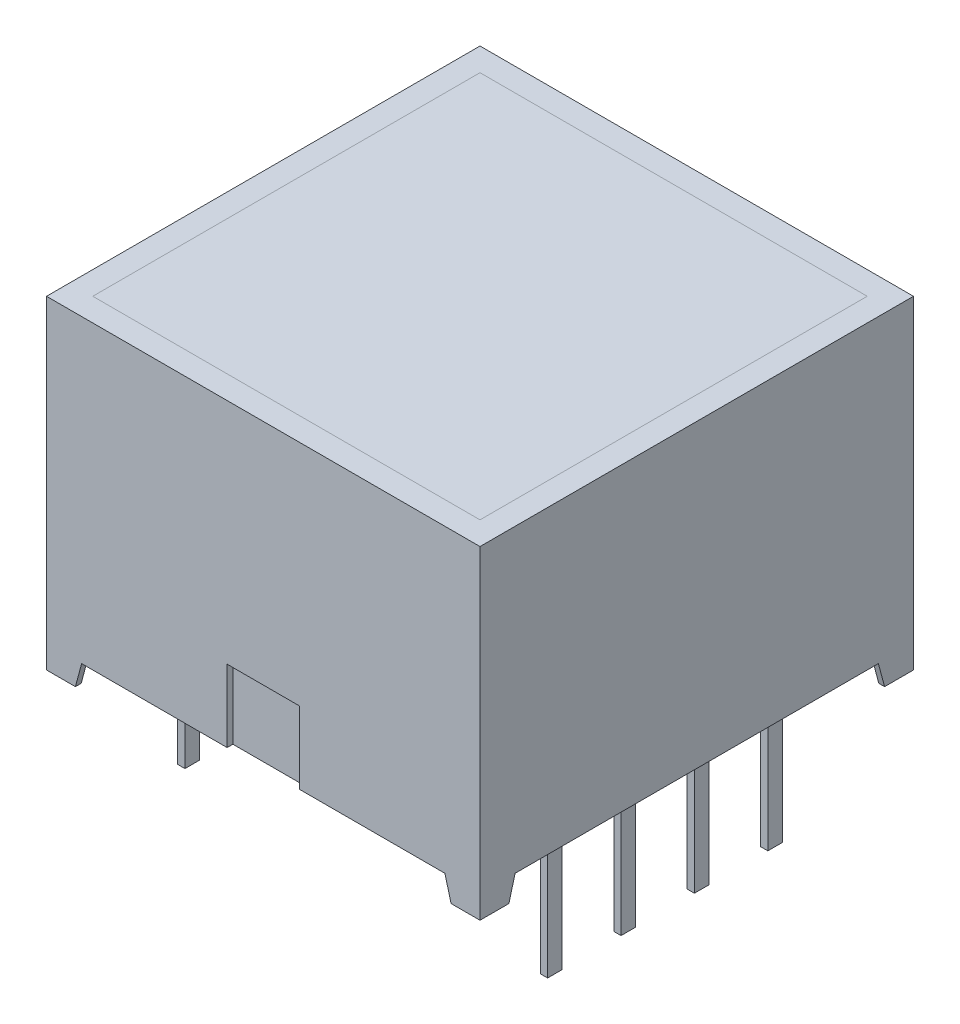
from build123d import *

# Parameters (mm, degrees)
EXTRUDE1_DEPTH     = 7.5
CUT_EXTRUDE1_DEPTH = 16
SKETCH2_W          = 13.4
SKETCH2_H          = 13.4
CUT_EXTRUDE2_DEPTH = 5.6
SKETCH4_W          = 0.25
SKETCH4_H          = 0.5
EXTRUDE2_DEPTH     = 0.8
SKETCH4_3_W        = 0.25
SKETCH4_3_H        = 0.5
EXTRUDE3_DEPTH     = 4
SKETCH4_4_W        = 1.014359354
SKETCH4_4_H        = 1.014359354
CUT_EXTRUDE3_DEPTH = 0.8
SKETCH2_3_W        = 13.4
SKETCH2_3_H        = 13.4
EXTRUDE4_DEPTH     = 5.6
SKETCH5_W          = 2.5
SKETCH5_H          = 2.5
CUT_EXTRUDE4_DEPTH = 0.2
SKETCH6_W          = 0.025316455
SKETCH6_H          = 0.026582279
CUT_EXTRUDE5_DEPTH = 0.01


with BuildPart() as part:
    # Sketch1 → Extrude1 (new body, symmetric)
    with BuildSketch(Plane(origin=(0, 0, 0), x_dir=(0, 0, -1), z_dir=(1, 0, 0))):
        Polygon((7.5, 5.6), (-7.5, 5.6), (7.5, -5.6), align=None)
        Polygon((7.5, -5.6), (-7.5, 5.6), (-7.5, -5.6), (-6.5, -5.6), (-6.285640646, -4.8), (6.285640646, -4.8), (6.5, -5.6), align=None)
    extrude(amount=EXTRUDE1_DEPTH, both=True)

    # Sketch3 → Cut-Extrude1 (cut, through all)
    with BuildSketch(Plane.XY.offset(7.5)):
        Polygon((-6.285640646, -4.8), (-6.5, -5.6), (6.5, -5.6), (6.285640646, -4.8), align=None)
    extrude(amount=-CUT_EXTRUDE1_DEPTH, mode=Mode.SUBTRACT)

    # Sketch2 → Cut-Extrude2 (cut)
    with BuildSketch(Plane(origin=(0, 5.6, 0), x_dir=(-1, 0, 0), z_dir=(0, 1, 0))):
        Rectangle(SKETCH2_W, SKETCH2_H)
    extrude(amount=-CUT_EXTRUDE2_DEPTH, mode=Mode.SUBTRACT)

    # Sketch4 → Extrude2 (add)
    with BuildSketch(Plane.XZ.offset(5.6)):
        with Locations((-6.275, 3.81)):
            Rectangle(SKETCH4_W, SKETCH4_H)
        with Locations((-6.275, 1.27)):
            Rectangle(SKETCH4_W, SKETCH4_H)
        with Locations((-6.275, -3.81)):
            Rectangle(SKETCH4_W, SKETCH4_H)
        with Locations((-6.275, -1.27)):
            Rectangle(SKETCH4_W, SKETCH4_H)
        with Locations((6.275, -3.81)):
            Rectangle(SKETCH4_W, SKETCH4_H)
        with Locations((6.275, -1.27)):
            Rectangle(SKETCH4_W, SKETCH4_H)
        with Locations((6.275, 1.27)):
            Rectangle(SKETCH4_W, SKETCH4_H)
        with Locations((6.275, 3.81)):
            Rectangle(SKETCH4_W, SKETCH4_H)
    extrude(amount=-EXTRUDE2_DEPTH)

    # Sketch4_3 → Extrude3 (add)
    with BuildSketch(Plane.XZ.offset(5.6)):
        with Locations((-6.275, 3.81)):
            Rectangle(SKETCH4_3_W, SKETCH4_3_H)
        with Locations((-6.275, 1.27)):
            Rectangle(SKETCH4_3_W, SKETCH4_3_H)
        with Locations((-6.275, -3.81)):
            Rectangle(SKETCH4_3_W, SKETCH4_3_H)
        with Locations((-6.275, -1.27)):
            Rectangle(SKETCH4_3_W, SKETCH4_3_H)
        with Locations((6.275, -3.81)):
            Rectangle(SKETCH4_3_W, SKETCH4_3_H)
        with Locations((6.275, -1.27)):
            Rectangle(SKETCH4_3_W, SKETCH4_3_H)
        with Locations((6.275, 1.27)):
            Rectangle(SKETCH4_3_W, SKETCH4_3_H)
        with Locations((6.275, 3.81)):
            Rectangle(SKETCH4_3_W, SKETCH4_3_H)
    extrude(amount=EXTRUDE3_DEPTH)

    # Sketch4_4 → Cut-Extrude3 (cut)
    with BuildSketch(Plane.XZ.offset(5.6)):
        with Locations((6.792820323, -6.792820323)):
            Rectangle(SKETCH4_4_W, SKETCH4_4_H)
        with Locations((-6.792820323, 6.792820323)):
            Rectangle(SKETCH4_4_W, SKETCH4_4_H)
        with Locations((6.792820323, 6.792820323)):
            Rectangle(SKETCH4_4_W, SKETCH4_4_H)
        with Locations((-6.792820323, -6.792820323)):
            Rectangle(SKETCH4_4_W, SKETCH4_4_H)
    extrude(amount=-CUT_EXTRUDE3_DEPTH, mode=Mode.SUBTRACT)

    # Sketch5 → Cut-Extrude4 (cut)
    with BuildSketch(Plane(origin=(0, 0, 7.5), x_dir=(-1, 0, 0), z_dir=(0, 0, -1))):
        with Locations((0, -3.55)):
            Rectangle(SKETCH5_W, SKETCH5_H)
    extrude(amount=CUT_EXTRUDE4_DEPTH, mode=Mode.SUBTRACT)

    # Sketch6 → Cut-Extrude5 (cut)
    with BuildSketch(Plane.XZ.offset(4.8)):
        Polygon((-0.663098825, -6.351662565), (-0.686556104, -6.426346109), (-0.711298983, -6.426346109), (-0.727715122, -6.376009875), (-0.74324123, -6.426346109), (-0.768973034, -6.426346109), (-0.792212749, -6.351662565), (-0.767034743, -6.351662565), (-0.754040281, -6.403145951), (-0.737624141, -6.351662565), (-0.716124933, -6.351662565), (-0.699807686, -6.403145951), (-0.68699123, -6.351662565), align=None)
        Polygon((-0.52892161, -6.351662565), (-0.552378888, -6.426346109), (-0.577121768, -6.426346109), (-0.593537907, -6.376009875), (-0.609064015, -6.426346109), (-0.634795819, -6.426346109), (-0.658035534, -6.351662565), (-0.632857528, -6.351662565), (-0.619863066, -6.403145951), (-0.603446926, -6.351662565), (-0.581947717, -6.351662565), (-0.565630471, -6.403145951), (-0.552814015, -6.351662565), align=None)
        Polygon((-0.394744395, -6.351662565), (-0.418201673, -6.426346109), (-0.442944553, -6.426346109), (-0.459360692, -6.376009875), (-0.4748868, -6.426346109), (-0.500618604, -6.426346109), (-0.523858319, -6.351662565), (-0.498680312, -6.351662565), (-0.48568585, -6.403145951), (-0.469269711, -6.351662565), (-0.447770502, -6.351662565), (-0.431453255, -6.403145951), (-0.4186368, -6.351662565), align=None)
        with Locations((-0.366896294, -6.41305497)):
            Rectangle(SKETCH6_W, SKETCH6_H)
        with BuildLine():
            add(Edge.make_bspline(
                [(-0.250440597, -6.395175223), (-0.250477086, -6.396397364), (-0.250548739, -6.398797242), (-0.251158456, -6.402304821), (-0.252151942, -6.405629526), (-0.25352606, -6.408792186), (-0.255314863, -6.411770805), (-0.257524453, -6.414551082), (-0.260088866, -6.417185882), (-0.263055075, -6.419592012), (-0.266335185, -6.421796389), (-0.269932761, -6.423693388), (-0.273811465, -6.425289871), (-0.277960051, -6.426628422), (-0.28240649, -6.427617003), (-0.28712402, -6.428340948), (-0.292117439, -6.428814278), (-0.295541017, -6.428856244), (-0.297295819, -6.428877755)],
                knots=[0, 0, 0, 0, 0.907352243, 1.781736951, 2.63548328, 3.47985091, 4.336556021, 5.208523475, 6.112432747, 7.062451073, 8.040435374, 9.043840564, 10.077958095, 11.152835584, 12.277940427, 13.457536469, 14.696825396, 16, 16, 16, 16], degree=3))
            add(Edge.make_bspline(
                [(-0.297295819, -6.428877755), (-0.299314074, -6.428853683), (-0.303223256, -6.428807058), (-0.308886781, -6.428378459), (-0.314154819, -6.42773232), (-0.319050533, -6.426765778), (-0.323655133, -6.425565013), (-0.3280884, -6.424273721), (-0.332369712, -6.422809306), (-0.335142802, -6.421709148), (-0.336516547, -6.421164147)],
                knots=[0, 0, 0, 0, 1.203215828, 2.33052265, 3.384689099, 4.366106119, 5.303329643, 6.221311756, 7.118865988, 8, 8, 8, 8], degree=3))
            Line((-0.336516547, -6.421164147), (-0.336516547, -6.397232185))
            Line((-0.336516547, -6.397232185), (-0.333668445, -6.397232185))
            add(Edge.make_bspline(
                [(-0.333668445, -6.397232185), (-0.332303131, -6.39831364), (-0.329580519, -6.400470201), (-0.325147286, -6.403232806), (-0.32049964, -6.405634969), (-0.315654169, -6.407608971), (-0.310757324, -6.409195295), (-0.305881947, -6.410288822), (-0.301116359, -6.411036171), (-0.29795779, -6.411116678), (-0.296405787, -6.411156236)],
                knots=[0, 0, 0, 0, 1.030622468, 2.055194264, 3.087043286, 4.125157485, 5.149848264, 6.130935704, 7.081611712, 8, 8, 8, 8], degree=3))
            add(Edge.make_bspline(
                [(-0.296405787, -6.411156236), (-0.295977011, -6.411155312), (-0.295059034, -6.411153335), (-0.293597507, -6.411025607), (-0.291945696, -6.410930031), (-0.290173188, -6.410722847), (-0.288376461, -6.410500986), (-0.28671406, -6.410126061), (-0.285204465, -6.409761194), (-0.284297944, -6.409393196), (-0.28386623, -6.409217944)],
                knots=[0, 0, 0, 0, 0.806402781, 1.726445712, 2.758724871, 3.919014682, 5.083870887, 6.16165551, 7.124521387, 8, 8, 8, 8], degree=3))
            add(Edge.make_bspline(
                [(-0.28386623, -6.409217944), (-0.283386667, -6.408989803), (-0.282444224, -6.408541455), (-0.281150624, -6.407731137), (-0.279982944, -6.406847672), (-0.278925573, -6.405882741), (-0.278051292, -6.404716991), (-0.277427425, -6.403308318), (-0.277082533, -6.4016593), (-0.277043509, -6.400484097), (-0.277022876, -6.399862723)],
                knots=[0, 0, 0, 0, 1.024747072, 2.013846092, 2.940605744, 3.850156746, 4.769278501, 5.73222711, 6.800942666, 8, 8, 8, 8], degree=3))
            add(Edge.make_bspline(
                [(-0.277022876, -6.399862723), (-0.27705472, -6.399317086), (-0.277117336, -6.398244202), (-0.277694529, -6.396709087), (-0.278603967, -6.395299919), (-0.279885558, -6.394031144), (-0.281478733, -6.392881611), (-0.283421117, -6.391899305), (-0.285671238, -6.391026118), (-0.287315309, -6.39060814), (-0.288177939, -6.39038883)],
                knots=[0, 0, 0, 0, 0.82557554, 1.623324704, 2.456147571, 3.35491006, 4.343819762, 5.427079081, 6.650009487, 8, 8, 8, 8], degree=3))
            add(Edge.make_bspline(
                [(-0.288177939, -6.39038883), (-0.290146565, -6.38994059), (-0.294185575, -6.38902094), (-0.3003354, -6.387882186), (-0.306463751, -6.386607326), (-0.310416517, -6.385400683), (-0.312347243, -6.384811299)],
                knots=[0, 0, 0, 0, 0.976100998, 2.002656142, 3.024398856, 4, 4, 4, 4], degree=3))
            add(Edge.make_bspline(
                [(-0.312347243, -6.384811299), (-0.313385761, -6.384458309), (-0.315407334, -6.383771181), (-0.318298845, -6.382609521), (-0.320960073, -6.381339691), (-0.323399786, -6.379984136), (-0.325600475, -6.378511596), (-0.327594743, -6.376970219), (-0.329357859, -6.375330179), (-0.330904664, -6.373590413), (-0.332229567, -6.37173971), (-0.333381952, -6.369794512), (-0.334364572, -6.367739093), (-0.33514261, -6.36556887), (-0.335767249, -6.363295214), (-0.336186231, -6.360917502), (-0.336485248, -6.358434373), (-0.336505972, -6.356739988), (-0.336516547, -6.355875381)],
                knots=[0, 0, 0, 0, 1.287047841, 2.5053592, 3.654260482, 4.74538952, 5.777514103, 6.75871007, 7.700244599, 8.599107454, 9.48590269, 10.366941872, 11.24940663, 12.154970331, 13.068988358, 14.012872203, 14.986013017, 16, 16, 16, 16], degree=3))
            add(Edge.make_bspline(
                [(-0.336516547, -6.355875381), (-0.336479245, -6.354719236), (-0.336405835, -6.352443964), (-0.335804406, -6.34911492), (-0.334777817, -6.345966183), (-0.333391753, -6.34296272), (-0.331563125, -6.340149634), (-0.329378331, -6.337471087), (-0.326754283, -6.334999495), (-0.323777162, -6.332699162), (-0.320489777, -6.330619763), (-0.316950794, -6.328789207), (-0.313181505, -6.327252555), (-0.309195958, -6.325978661), (-0.304977489, -6.32502399), (-0.300540256, -6.324305059), (-0.295866468, -6.323891877), (-0.292675046, -6.323840627), (-0.291045819, -6.323814463)],
                knots=[0, 0, 0, 0, 0.894990994, 1.761326291, 2.609044902, 3.454222546, 4.315366365, 5.200560057, 6.125081389, 7.100429509, 8.110379559, 9.133447974, 10.182136699, 11.259192205, 12.370181258, 13.528580438, 14.738335141, 16, 16, 16, 16], degree=3))
            add(Edge.make_bspline(
                [(-0.291045819, -6.323814463), (-0.289377125, -6.323836616), (-0.286042566, -6.323880884), (-0.281061227, -6.324259441), (-0.276106798, -6.324811753), (-0.271244374, -6.325660993), (-0.266552211, -6.326629225), (-0.262133096, -6.327728498), (-0.258053544, -6.328966005), (-0.255479891, -6.329920406), (-0.254238066, -6.330380919)],
                knots=[0, 0, 0, 0, 1.065407564, 2.129008667, 3.188544425, 4.247469455, 5.279542408, 6.247502114, 7.154394069, 8, 8, 8, 8], degree=3))
            Line((-0.254238066, -6.330380919), (-0.254238066, -6.352928387))
            Line((-0.254238066, -6.352928387), (-0.257066388, -6.352928387))
            add(Edge.make_bspline(
                [(-0.257066388, -6.352928387), (-0.258139892, -6.3521291), (-0.260330669, -6.350497934), (-0.263980273, -6.348396199), (-0.267947893, -6.346456107), (-0.27222952, -6.34476445), (-0.2766893, -6.343306443), (-0.281272059, -6.342286885), (-0.285898275, -6.341645178), (-0.288999979, -6.341572389), (-0.290551357, -6.341535982)],
                knots=[0, 0, 0, 0, 0.892265782, 1.820912499, 2.804518821, 3.836954028, 4.889985052, 5.931488012, 6.965393252, 8, 8, 8, 8], degree=3))
            add(Edge.make_bspline(
                [(-0.290551357, -6.341535982), (-0.291646962, -6.341557885), (-0.293844605, -6.341601819), (-0.297113797, -6.341986705), (-0.300354275, -6.342625557), (-0.302388957, -6.343441609), (-0.303407369, -6.343850065)],
                knots=[0, 0, 0, 0, 0.999122297, 2.004111588, 3.001004448, 4, 4, 4, 4], degree=3))
            add(Edge.make_bspline(
                [(-0.303407369, -6.343850065), (-0.303841099, -6.344051244), (-0.304708269, -6.344453467), (-0.305915811, -6.345233093), (-0.307036783, -6.346149436), (-0.308032365, -6.347202193), (-0.308876799, -6.348370547), (-0.309495826, -6.34963813), (-0.309870318, -6.351002011), (-0.309912665, -6.35193711), (-0.309934268, -6.352414147)],
                knots=[0, 0, 0, 0, 1.004925302, 2.009180302, 3.014392739, 4.04465309, 5.049195417, 6.035570224, 6.99785458, 8, 8, 8, 8], degree=3))
            add(Edge.make_bspline(
                [(-0.309934268, -6.352414147), (-0.30989983, -6.353052312), (-0.309834022, -6.354271788), (-0.309227437, -6.355987584), (-0.308242604, -6.357466018), (-0.307081999, -6.358460938), (-0.30596487, -6.359158376), (-0.30492921, -6.359668886), (-0.303719983, -6.360152245), (-0.302348735, -6.360649714), (-0.300812408, -6.361140901), (-0.299103851, -6.361616448), (-0.297221134, -6.362065744), (-0.295905259, -6.362351934), (-0.295219078, -6.362501172)],
                knots=[0, 0, 0, 0, 1.173816843, 2.243057204, 3.312297565, 4.415174738, 5.03266065, 5.73970059, 6.541434878, 7.433956553, 8.430083051, 9.515931566, 10.70464786, 12, 12, 12, 12], degree=3))
            add(Edge.make_bspline(
                [(-0.295219078, -6.362501172), (-0.293386156, -6.362876617), (-0.289791189, -6.363612988), (-0.284391965, -6.364725353), (-0.278886977, -6.365990712), (-0.275215826, -6.367142708), (-0.273304521, -6.36774247)],
                knots=[0, 0, 0, 0, 0.995749986, 1.952994291, 2.934271555, 4, 4, 4, 4], degree=3))
            add(Edge.make_bspline(
                [(-0.273304521, -6.36774247), (-0.272358033, -6.368061829), (-0.270506549, -6.368686546), (-0.267865002, -6.36977123), (-0.265415949, -6.37095332), (-0.263137678, -6.372175806), (-0.261075597, -6.373539022), (-0.259182373, -6.37495367), (-0.257499354, -6.376481778), (-0.256001405, -6.378094637), (-0.254683004, -6.379805069), (-0.25354804, -6.381643171), (-0.252584894, -6.3835977), (-0.251776763, -6.385670772), (-0.251198746, -6.38787784), (-0.250764688, -6.390204141), (-0.250473866, -6.392649456), (-0.250451811, -6.394323903), (-0.250440597, -6.395175223)],
                knots=[0, 0, 0, 0, 1.237386967, 2.420528625, 3.534815053, 4.605870898, 5.620827102, 6.594482803, 7.531295079, 8.432978826, 9.318460435, 10.202471551, 11.10474705, 12.014900263, 12.954095338, 13.926516828, 14.945802342, 16, 16, 16, 16], degree=3))
        make_face()
        with BuildLine():
            Line((-0.158035534, -6.426346109), (-0.182086167, -6.426346109))
            Line((-0.182086167, -6.426346109), (-0.182086167, -6.41851383))
            add(Edge.make_bspline(
                [(-0.182086167, -6.41851383), (-0.183179422, -6.419322498), (-0.185287202, -6.420881596), (-0.188460942, -6.422960361), (-0.191489663, -6.424743523), (-0.194411264, -6.426285675), (-0.197426619, -6.427476523), (-0.200654122, -6.428298379), (-0.204156386, -6.428799498), (-0.20658336, -6.42885109), (-0.207837749, -6.428877755)],
                knots=[0, 0, 0, 0, 1.150906677, 2.218931226, 3.20955724, 4.125565256, 5.012676028, 5.946647191, 6.938718366, 8, 8, 8, 8], degree=3))
            add(Edge.make_bspline(
                [(-0.207837749, -6.428877755), (-0.208854094, -6.428855025), (-0.210833212, -6.428810765), (-0.213710542, -6.428466028), (-0.216417853, -6.427927881), (-0.218934003, -6.427122025), (-0.221299349, -6.426147909), (-0.223450867, -6.424888821), (-0.225438556, -6.423429484), (-0.227241934, -6.421752549), (-0.228832553, -6.419831587), (-0.230219604, -6.417708836), (-0.231395416, -6.415374197), (-0.232337054, -6.412822831), (-0.233091987, -6.410064386), (-0.233615965, -6.40708518), (-0.233936544, -6.40389804), (-0.233968485, -6.401702912), (-0.233984901, -6.400574748)],
                knots=[0, 0, 0, 0, 1.108935798, 2.159418225, 3.158520219, 4.116592843, 5.038730546, 5.944611115, 6.829677354, 7.725673622, 8.624842385, 9.544872214, 10.487719724, 11.471363217, 12.50822837, 13.604887271, 14.769056852, 16, 16, 16, 16], degree=3))
            Line((-0.233984901, -6.400574748), (-0.233984901, -6.351662565))
            Line((-0.233984901, -6.351662565), (-0.209934268, -6.351662565))
            Line((-0.209934268, -6.351662565), (-0.209934268, -6.389241679))
            add(Edge.make_bspline(
                [(-0.209934268, -6.389241679), (-0.209932633, -6.39015815), (-0.209929502, -6.391912365), (-0.209847163, -6.394418172), (-0.209726262, -6.396686344), (-0.209587558, -6.398728373), (-0.209334541, -6.400575124), (-0.208956833, -6.402241285), (-0.208486007, -6.403760887), (-0.208021688, -6.404667588), (-0.207798192, -6.40510402)],
                knots=[0, 0, 0, 0, 1.361401701, 2.605856924, 3.723918663, 4.735739235, 5.645738665, 6.489217889, 7.27279937, 8, 8, 8, 8], degree=3))
            add(Edge.make_bspline(
                [(-0.207798192, -6.40510402), (-0.207568152, -6.405502668), (-0.207115914, -6.406286375), (-0.206196103, -6.407293523), (-0.20512012, -6.40813043), (-0.203850481, -6.408803074), (-0.2023574, -6.409286777), (-0.200625399, -6.409633524), (-0.198639384, -6.409847348), (-0.197230465, -6.40987551), (-0.196484901, -6.409890413)],
                knots=[0, 0, 0, 0, 0.849057291, 1.669173542, 2.503217716, 3.359509317, 4.311793648, 5.394940091, 6.621469141, 8, 8, 8, 8], degree=3))
            add(Edge.make_bspline(
                [(-0.196484901, -6.409890413), (-0.195943636, -6.409872955), (-0.194830759, -6.409837062), (-0.193125547, -6.409607133), (-0.191336518, -6.409245477), (-0.188822321, -6.408586454), (-0.185646176, -6.407407275), (-0.183282037, -6.406048474), (-0.182086167, -6.405361141)],
                knots=[0, 0, 0, 0, 0.638164724, 1.312110757, 2.025558264, 2.789159289, 4.375836335, 6, 6, 6, 6], degree=3))
            Line((-0.182086167, -6.405361141), (-0.182086167, -6.351662565))
            Line((-0.182086167, -6.351662565), (-0.158035534, -6.351662565))
            Line((-0.158035534, -6.351662565), (-0.158035534, -6.426346109))
        make_face()
        with BuildLine():
            Line((-0.060567179, -6.426346109), (-0.084617812, -6.426346109))
            Line((-0.084617812, -6.426346109), (-0.084617812, -6.388766995))
            add(Edge.make_bspline(
                [(-0.084617812, -6.388766995), (-0.084638137, -6.387236522), (-0.084678672, -6.384184109), (-0.085012251, -6.380427334), (-0.085345961, -6.377579543), (-0.085722784, -6.375743476), (-0.08615297, -6.37419514), (-0.086565416, -6.373309403), (-0.086753888, -6.372904653)],
                knots=[0, 0, 0, 0, 1.709235885, 3.408940626, 4.211008593, 4.910095588, 5.501954032, 6, 6, 6, 6], degree=3))
            add(Edge.make_bspline(
                [(-0.086753888, -6.372904653), (-0.086998317, -6.372506531), (-0.087477553, -6.371725956), (-0.088415369, -6.370713934), (-0.089512018, -6.36987772), (-0.090790741, -6.36921277), (-0.092275395, -6.368726872), (-0.093988069, -6.368340213), (-0.095974039, -6.368171653), (-0.097381408, -6.368136743), (-0.098126515, -6.368118261)],
                knots=[0, 0, 0, 0, 0.860145871, 1.686437142, 2.528070002, 3.393017362, 4.331453407, 5.402595683, 6.624848233, 8, 8, 8, 8], degree=3))
            add(Edge.make_bspline(
                [(-0.098126515, -6.368118261), (-0.099258405, -6.368174841), (-0.101569638, -6.368290374), (-0.104430929, -6.369003966), (-0.106757804, -6.369816263), (-0.108603425, -6.3705905), (-0.110519954, -6.371545125), (-0.111803378, -6.372272199), (-0.112465914, -6.372647533)],
                knots=[0, 0, 0, 0, 1.338419466, 2.732951426, 3.468143565, 4.254837763, 5.099104234, 6, 6, 6, 6], degree=3))
            Line((-0.112465914, -6.372647533), (-0.112465914, -6.426346109))
            Line((-0.112465914, -6.426346109), (-0.136516547, -6.426346109))
            Line((-0.136516547, -6.426346109), (-0.136516547, -6.351662565))
            Line((-0.136516547, -6.351662565), (-0.112465914, -6.351662565))
            Line((-0.112465914, -6.351662565), (-0.112465914, -6.359494843))
            add(Edge.make_bspline(
                [(-0.112465914, -6.359494843), (-0.111408676, -6.358688405), (-0.109350701, -6.357118626), (-0.106173948, -6.355085217), (-0.103103236, -6.35327536), (-0.100048715, -6.351763226), (-0.096924217, -6.350564626), (-0.093656586, -6.349749023), (-0.090239874, -6.349206075), (-0.087903201, -6.349156263), (-0.086714331, -6.349130919)],
                knots=[0, 0, 0, 0, 1.126064518, 2.191951536, 3.19307265, 4.144813015, 5.076393104, 6.021983703, 6.993610568, 8, 8, 8, 8], degree=3))
            add(Edge.make_bspline(
                [(-0.086714331, -6.349130919), (-0.08571806, -6.349156308), (-0.083773161, -6.349205872), (-0.0809384, -6.349515582), (-0.07826698, -6.350066246), (-0.075774705, -6.350864075), (-0.073432088, -6.351849688), (-0.071270132, -6.353081199), (-0.069278106, -6.354539638), (-0.067449537, -6.35620058), (-0.065819356, -6.358090538), (-0.06439987, -6.360206911), (-0.063228446, -6.362555639), (-0.062219614, -6.365102776), (-0.061485389, -6.367880546), (-0.060958938, -6.370871312), (-0.060608508, -6.374076494), (-0.060581231, -6.376292394), (-0.060567179, -6.377433925)],
                knots=[0, 0, 0, 0, 1.088441561, 2.124831547, 3.110816719, 4.062969431, 4.979391633, 5.88258537, 6.774334107, 7.671621258, 8.575503974, 9.49441354, 10.447872957, 11.437639084, 12.482478955, 13.580222388, 14.753440527, 16, 16, 16, 16], degree=3))
            Line((-0.060567179, -6.377433925), (-0.060567179, -6.426346109))
        make_face()
        Polygon((0.034369529, -6.426346109), (-0.037782369, -6.426346109), (-0.037782369, -6.326346109), (-0.012465914, -6.326346109), (-0.012465914, -6.407358767), (0.034369529, -6.407358767), align=None)
        Polygon((0.121711302, -6.426346109), (0.049559403, -6.426346109), (0.049559403, -6.326346109), (0.121711302, -6.326346109), (0.121711302, -6.345333451), (0.074875859, -6.345333451), (0.074875859, -6.36305497), (0.117913833, -6.36305497), (0.117913833, -6.382042312), (0.074875859, -6.382042312), (0.074875859, -6.407358767), (0.121711302, -6.407358767), align=None)
        with BuildLine():
            add(Edge.make_bspline(
                [(0.238166998, -6.376445001), (0.238147682, -6.37759269), (0.23810943, -6.379865576), (0.237814239, -6.383230383), (0.237288214, -6.386496058), (0.236609032, -6.389680307), (0.235686526, -6.392759235), (0.234604813, -6.395766812), (0.233295167, -6.398672305), (0.231790314, -6.40147374), (0.230140842, -6.404145843), (0.228366093, -6.406666051), (0.226520314, -6.409049269), (0.224531001, -6.411244163), (0.222451819, -6.413286183), (0.220276291, -6.415176997), (0.217971227, -6.416880428), (0.216364064, -6.417903312), (0.215560194, -6.418414938)],
                knots=[0, 0, 0, 0, 1.105570398, 2.18947457, 3.250358341, 4.290584537, 5.323553275, 6.344225964, 7.367641686, 8.3905646, 9.405808457, 10.390761353, 11.358902336, 12.307789878, 13.241960776, 14.165076779, 15.082208636, 16, 16, 16, 16], degree=3))
            add(Edge.make_bspline(
                [(0.215560194, -6.418414938), (0.214320973, -6.419127108), (0.211836208, -6.420555081), (0.207852262, -6.422223212), (0.203721143, -6.423631169), (0.199362589, -6.424679358), (0.19471624, -6.425408091), (0.189721583, -6.425971142), (0.184320456, -6.426271506), (0.180585574, -6.426320675), (0.178653548, -6.426346109)],
                knots=[0, 0, 0, 0, 0.896298978, 1.797171328, 2.70531317, 3.633678302, 4.606491125, 5.655688921, 6.787306437, 8, 8, 8, 8], degree=3))
            Line((0.178653548, -6.426346109), (0.143230289, -6.426346109))
            Line((0.143230289, -6.426346109), (0.143230289, -6.326346109))
            Line((0.143230289, -6.326346109), (0.179662251, -6.326346109))
            add(Edge.make_bspline(
                [(0.179662251, -6.326346109), (0.181640975, -6.326362804), (0.185457688, -6.326395008), (0.190968106, -6.326810976), (0.196066485, -6.327410496), (0.200751064, -6.328337188), (0.205059471, -6.329445839), (0.208990493, -6.330808875), (0.212602382, -6.332307147), (0.214781209, -6.333580894), (0.215837093, -6.334198166)],
                knots=[0, 0, 0, 0, 1.267192274, 2.444256634, 3.537982003, 4.553396635, 5.500903572, 6.385021601, 7.217363933, 8, 8, 8, 8], degree=3))
            add(Edge.make_bspline(
                [(0.215837093, -6.334198166), (0.216688046, -6.334734707), (0.218380171, -6.33580162), (0.220781385, -6.337583472), (0.223010812, -6.339539549), (0.225139316, -6.341591368), (0.22711913, -6.343794256), (0.228962343, -6.346132959), (0.23066611, -6.348611066), (0.232224266, -6.351220486), (0.233644351, -6.353950726), (0.23483643, -6.356823071), (0.235875792, -6.359805944), (0.236721874, -6.362904884), (0.237378204, -6.366122273), (0.237824288, -6.369459754), (0.238107721, -6.372912942), (0.238147072, -6.375257736), (0.238166998, -6.376445001)],
                knots=[0, 0, 0, 0, 0.964043478, 1.917004671, 2.862223898, 3.805158963, 4.749279098, 5.698713747, 6.657523689, 7.629652222, 8.610369353, 9.604453025, 10.607693792, 11.636365947, 12.681120053, 13.752669011, 14.862083412, 16, 16, 16, 16], degree=3))
        make_face()
        with BuildLine():
            add(Edge.make_bspline(
                [(0.211584719, -6.376286774), (0.211574249, -6.37548206), (0.211553709, -6.373903568), (0.211365387, -6.371587393), (0.211094799, -6.369361343), (0.210705665, -6.36721771), (0.210165233, -6.365167563), (0.209533051, -6.363205993), (0.208805961, -6.36132707), (0.207925031, -6.359549411), (0.206951207, -6.357841073), (0.205803763, -6.356255546), (0.204555412, -6.354742663), (0.203177129, -6.353314678), (0.201634188, -6.352008782), (0.199974085, -6.350778706), (0.198173727, -6.34965038), (0.196900739, -6.34899033), (0.196256396, -6.348656236)],
                knots=[0, 0, 0, 0, 1.152052275, 2.259818351, 3.325348653, 4.362224493, 5.376551665, 6.358740615, 7.312387502, 8.258104984, 9.197203025, 10.124507262, 11.056413058, 12.004389423, 12.961766972, 13.947352551, 14.961020569, 16, 16, 16, 16], degree=3))
            add(Edge.make_bspline(
                [(0.196256396, -6.348656236), (0.195581499, -6.348349524), (0.194243805, -6.347741599), (0.192172982, -6.347010407), (0.190083598, -6.346437571), (0.187881999, -6.346006713), (0.185412239, -6.345684782), (0.182486657, -6.345487523), (0.179030748, -6.345345354), (0.176544033, -6.345337603), (0.175212093, -6.345333451)],
                knots=[0, 0, 0, 0, 0.826967603, 1.639107464, 2.447640171, 3.242670507, 4.14065217, 5.225198036, 6.513753944, 8, 8, 8, 8], degree=3))
            Line((0.175212093, -6.345333451), (0.168546745, -6.345333451))
            Line((0.168546745, -6.345333451), (0.168546745, -6.407358767))
            Line((0.168546745, -6.407358767), (0.175212093, -6.407358767))
            add(Edge.make_bspline(
                [(0.175212093, -6.407358767), (0.1759703, -6.407354021), (0.177434066, -6.407344859), (0.179550304, -6.407301746), (0.18151612, -6.407255032), (0.183320925, -6.407137994), (0.184973269, -6.407067495), (0.186459416, -6.406883824), (0.187796366, -6.406749349), (0.189368847, -6.406471626), (0.191224033, -6.406065651), (0.193390823, -6.405382493), (0.195531522, -6.404532919), (0.196920073, -6.40384784), (0.197621112, -6.403501963)],
                knots=[0, 0, 0, 0, 1.186805873, 2.291202465, 3.313317863, 4.264127762, 5.122212376, 5.900577546, 6.607154111, 7.224697658, 8.398873738, 9.57716935, 10.776782771, 12, 12, 12, 12], degree=3))
            add(Edge.make_bspline(
                [(0.197621112, -6.403501963), (0.198206225, -6.403160446), (0.199360146, -6.402486928), (0.200983686, -6.401352877), (0.202491276, -6.400145067), (0.203887753, -6.398856927), (0.205149339, -6.397467541), (0.206305427, -6.396008075), (0.207310814, -6.394447754), (0.208550068, -6.392258928), (0.209797158, -6.389234171), (0.210829557, -6.385261417), (0.211468705, -6.380902505), (0.211545057, -6.377864764), (0.211584719, -6.376286774)],
                knots=[0, 0, 0, 0, 0.755237594, 1.489427721, 2.205882609, 2.908165467, 3.605466573, 4.296695275, 4.981837198, 5.673065901, 7.099889822, 8.61390339, 10.241051878, 12, 12, 12, 12], degree=3))
        make_face(mode=Mode.SUBTRACT)
        with Locations((0.269812568, -6.41305497)):
            Rectangle(SKETCH6_W, SKETCH6_H)
        with BuildLine():
            add(Edge.make_bspline(
                [(0.344456555, -6.428877755), (0.342866438, -6.428855951), (0.339745294, -6.428813155), (0.335174006, -6.428336127), (0.330808641, -6.42761883), (0.326663017, -6.426596511), (0.322752474, -6.425255992), (0.319097524, -6.423585986), (0.315680852, -6.42161879), (0.313618932, -6.420033894), (0.312593422, -6.419245634)],
                knots=[0, 0, 0, 0, 1.123701398, 2.205645569, 3.245398653, 4.249180969, 5.220497262, 6.163202923, 7.086456062, 8, 8, 8, 8], degree=3))
            add(Edge.make_bspline(
                [(0.312593422, -6.419245634), (0.311641787, -6.418390801), (0.309742198, -6.416684441), (0.30727457, -6.413713897), (0.305156494, -6.410424924), (0.303344239, -6.406833272), (0.301912288, -6.402913386), (0.300919752, -6.398663492), (0.300292148, -6.394106162), (0.300226197, -6.390957958), (0.300192314, -6.389340571)],
                knots=[0, 0, 0, 0, 0.916342154, 1.829140869, 2.758848968, 3.716597128, 4.708179637, 5.743612459, 6.840783343, 8, 8, 8, 8], degree=3))
            add(Edge.make_bspline(
                [(0.300192314, -6.389340571), (0.300231075, -6.387637344), (0.300306197, -6.384336264), (0.300969957, -6.379564076), (0.302039569, -6.375146396), (0.303577127, -6.371094487), (0.305507569, -6.367401296), (0.307772062, -6.364029461), (0.310392588, -6.360986537), (0.312399726, -6.359241097), (0.31340434, -6.35836747)],
                knots=[0, 0, 0, 0, 1.171797512, 2.271099083, 3.308930235, 4.294129479, 5.24602549, 6.17106565, 7.084581485, 8, 8, 8, 8], degree=3))
            add(Edge.make_bspline(
                [(0.31340434, -6.35836747), (0.314430124, -6.357598691), (0.316494082, -6.356051848), (0.319893621, -6.354157035), (0.323505834, -6.352552518), (0.327336951, -6.351306632), (0.331317469, -6.350358095), (0.335383009, -6.349631123), (0.339529377, -6.349211098), (0.342319562, -6.349157774), (0.343724751, -6.349130919)],
                knots=[0, 0, 0, 0, 0.952097844, 1.915695341, 2.885641886, 3.886921822, 4.905719434, 5.925883802, 6.95543633, 8, 8, 8, 8], degree=3))
            add(Edge.make_bspline(
                [(0.343724751, -6.349130919), (0.344971478, -6.349147883), (0.347422965, -6.349181239), (0.351023898, -6.349503896), (0.354472483, -6.350034061), (0.357769795, -6.350777655), (0.360942943, -6.351670454), (0.364002415, -6.352701734), (0.366967231, -6.353839675), (0.368867909, -6.354723891), (0.369812567, -6.355163356)],
                knots=[0, 0, 0, 0, 1.107671842, 2.178058178, 3.209662749, 4.206063564, 5.179815947, 6.137646632, 7.07438927, 8, 8, 8, 8], degree=3))
            Line((0.369812567, -6.355163356), (0.369812567, -6.375713198))
            Line((0.369812567, -6.375713198), (0.366470004, -6.375713198))
            add(Edge.make_bspline(
                [(0.366470004, -6.375713198), (0.365971236, -6.375294971), (0.3648893, -6.374387747), (0.363087948, -6.372986734), (0.360954437, -6.371436168), (0.359303229, -6.370550165), (0.358420162, -6.37007633)],
                knots=[0, 0, 0, 0, 0.792878214, 1.719922066, 2.780612869, 4, 4, 4, 4], degree=3))
            add(Edge.make_bspline(
                [(0.358420162, -6.37007633), (0.357492503, -6.369633462), (0.355585474, -6.368723039), (0.353025497, -6.367903495), (0.350836466, -6.367324958), (0.349024583, -6.367072149), (0.347091162, -6.3668818), (0.345755892, -6.366862405), (0.345069688, -6.366852438)],
                knots=[0, 0, 0, 0, 1.33256682, 2.739414054, 3.480190821, 4.267897792, 5.109861573, 6, 6, 6, 6], degree=3))
            add(Edge.make_bspline(
                [(0.345069688, -6.366852438), (0.344304139, -6.366871998), (0.342820542, -6.366909903), (0.340658939, -6.367186825), (0.338640863, -6.36766556), (0.336736455, -6.368303971), (0.334997708, -6.369200211), (0.333355178, -6.370212479), (0.331880703, -6.371466986), (0.330538756, -6.372884727), (0.329351272, -6.37447524), (0.32832452, -6.376201728), (0.327441793, -6.378059621), (0.3267399, -6.380057529), (0.32618239, -6.382187391), (0.325792824, -6.384450201), (0.325551046, -6.386849799), (0.325523103, -6.388496094), (0.32550877, -6.389340571)],
                knots=[0, 0, 0, 0, 1.087094245, 2.106738054, 3.087824582, 4.029427112, 4.95060567, 5.859714611, 6.763601524, 7.690850518, 8.627131371, 9.576106403, 10.539384251, 11.543302637, 12.578856349, 13.662518017, 14.800975475, 16, 16, 16, 16], degree=3))
            add(Edge.make_bspline(
                [(0.32550877, -6.389340571), (0.325523544, -6.390204727), (0.32555225, -6.39188374), (0.325785765, -6.394325351), (0.326201656, -6.396606782), (0.326772904, -6.398732102), (0.327497252, -6.40069812), (0.328402369, -6.402495517), (0.329438725, -6.404152324), (0.330683283, -6.405614936), (0.332047167, -6.406931257), (0.333562059, -6.408067392), (0.335221298, -6.409015537), (0.337003478, -6.40982), (0.338936519, -6.410398398), (0.340993056, -6.41083509), (0.343182611, -6.411123647), (0.344692965, -6.41114521), (0.345465257, -6.411156236)],
                knots=[0, 0, 0, 0, 1.230336593, 2.390482092, 3.487897344, 4.52859895, 5.520747884, 6.465347575, 7.38981449, 8.296085817, 9.192433006, 10.084246191, 10.984321635, 11.908883871, 12.862027947, 13.850751296, 14.901019963, 16, 16, 16, 16], degree=3))
            add(Edge.make_bspline(
                [(0.345465257, -6.411156236), (0.3461911, -6.411148012), (0.347606102, -6.411131981), (0.349664524, -6.410915914), (0.351618442, -6.410636588), (0.353452988, -6.410195311), (0.355157237, -6.409660427), (0.35672289, -6.409089601), (0.358135497, -6.408485321), (0.358996832, -6.408017705), (0.359409086, -6.407793894)],
                knots=[0, 0, 0, 0, 1.200879421, 2.341068892, 3.423000803, 4.465923194, 5.460027553, 6.378409259, 7.223869634, 8, 8, 8, 8], degree=3))
            add(Edge.make_bspline(
                [(0.359409086, -6.407793894), (0.360117443, -6.407366208), (0.361478816, -6.406544249), (0.363303934, -6.405123789), (0.36494806, -6.403717349), (0.365972165, -6.402760581), (0.366470004, -6.402295476)],
                knots=[0, 0, 0, 0, 1.105932972, 2.12546697, 3.088749538, 4, 4, 4, 4], degree=3))
            Line((0.366470004, -6.402295476), (0.369812567, -6.402295476))
            Line((0.369812567, -6.402295476), (0.369812567, -6.423003546))
            add(Edge.make_bspline(
                [(0.369812567, -6.423003546), (0.368867191, -6.423441088), (0.36697621, -6.424316277), (0.364061432, -6.425469428), (0.36106819, -6.426442307), (0.35801696, -6.427334654), (0.354847328, -6.428032849), (0.351529979, -6.428522079), (0.348048674, -6.428823818), (0.345670258, -6.42885953), (0.344456555, -6.428877755)],
                knots=[0, 0, 0, 0, 0.952024047, 1.90427691, 2.862762905, 3.827874523, 4.80891974, 5.826446878, 6.890837857, 8, 8, 8, 8], degree=3))
        make_face()
        with BuildLine():
            add(Edge.make_bspline(
                [(0.462217631, -6.389043894), (0.462192711, -6.390548726), (0.462144135, -6.393482047), (0.461607927, -6.397754867), (0.460784465, -6.401785308), (0.45965114, -6.405586146), (0.458133287, -6.409129192), (0.456290873, -6.412425146), (0.454117282, -6.415477328), (0.451626963, -6.418267555), (0.448825478, -6.420765747), (0.445751712, -6.42296194), (0.442381845, -6.424768988), (0.4387731, -6.426295537), (0.434883793, -6.427451638), (0.430724698, -6.428269589), (0.426307188, -6.42880392), (0.423268823, -6.428852733), (0.421711302, -6.428877755)],
                knots=[0, 0, 0, 0, 1.120122129, 2.18341868, 3.201215738, 4.181270334, 5.131540819, 6.065757527, 6.988093576, 7.916512302, 8.844931028, 9.778115023, 10.722851943, 11.686686084, 12.691660064, 13.738321946, 14.84062285, 16, 16, 16, 16], degree=3))
            add(Edge.make_bspline(
                [(0.421711302, -6.428877755), (0.420153753, -6.428852815), (0.417115335, -6.428804163), (0.412698201, -6.428268693), (0.408543981, -6.427455975), (0.404659329, -6.42628674), (0.401045019, -6.42477465), (0.397671191, -6.422961208), (0.394597009, -6.420765955), (0.391795807, -6.418267445), (0.38930477, -6.41547756), (0.387133765, -6.41242433), (0.385282826, -6.409134538), (0.383802434, -6.405577263), (0.382629902, -6.401790055), (0.381817123, -6.397754057), (0.381277806, -6.393482266), (0.381229668, -6.3905488), (0.381204972, -6.389043894)],
                knots=[0, 0, 0, 0, 1.159424321, 2.261770074, 3.308474541, 4.308788811, 5.277191138, 6.221966496, 7.15518846, 8.08364496, 9.01210146, 9.934475036, 10.868729753, 11.817121636, 12.798654016, 13.816492484, 14.879832297, 16, 16, 16, 16], degree=3))
            add(Edge.make_bspline(
                [(0.381204972, -6.389043894), (0.381230095, -6.38753247), (0.381279181, -6.38457946), (0.38181455, -6.380280587), (0.382632568, -6.376219936), (0.3837926, -6.372411623), (0.385308873, -6.368860023), (0.387149898, -6.365557919), (0.389346365, -6.362511344), (0.391855864, -6.359721592), (0.394667658, -6.357225211), (0.397761589, -6.355052306), (0.401113509, -6.353215648), (0.404720708, -6.351693815), (0.408607263, -6.35055925), (0.412744206, -6.349741671), (0.4171416, -6.349203599), (0.420160338, -6.349155587), (0.421711302, -6.349130919)],
                knots=[0, 0, 0, 0, 1.124034801, 2.196132384, 3.217834281, 4.203147447, 5.152578239, 6.085969439, 7.010345409, 7.941219594, 8.872481455, 9.802010446, 10.748267785, 11.711250247, 12.709230373, 13.754967386, 14.846549946, 16, 16, 16, 16], degree=3))
            add(Edge.make_bspline(
                [(0.421711302, -6.349130919), (0.423282045, -6.349155631), (0.426340221, -6.349203745), (0.43078355, -6.349740084), (0.434957681, -6.35055261), (0.438855289, -6.35172068), (0.442479297, -6.353223949), (0.445826474, -6.355078896), (0.448911432, -6.357253246), (0.451679695, -6.359783074), (0.454163454, -6.362578028), (0.45632581, -6.365635708), (0.458161286, -6.368943284), (0.459637029, -6.372505159), (0.460811231, -6.376297791), (0.461631643, -6.380332218), (0.462137795, -6.384607125), (0.462190556, -6.387539268), (0.462217631, -6.389043894)],
                knots=[0, 0, 0, 0, 1.167473013, 2.273023816, 3.322954552, 4.326451713, 5.293391623, 6.234801871, 7.166614545, 8.093305908, 9.017100806, 9.942078766, 10.872536262, 11.824015763, 12.804065898, 13.820367293, 14.881523901, 16, 16, 16, 16], degree=3))
        make_face()
        with BuildLine():
            add(Edge.make_bspline(
                [(0.432510352, -6.407536774), (0.432865098, -6.40703658), (0.433587048, -6.406018628), (0.434462988, -6.404323436), (0.435222641, -6.402492169), (0.435841328, -6.400465886), (0.43635147, -6.398168108), (0.43665309, -6.395511177), (0.436885904, -6.392476291), (0.436895885, -6.390323483), (0.436901175, -6.389182343)],
                knots=[0, 0, 0, 0, 0.765094823, 1.557058493, 2.376706509, 3.238810155, 4.199844458, 5.312104478, 6.575226644, 8, 8, 8, 8], degree=3))
            add(Edge.make_bspline(
                [(0.436901175, -6.389182343), (0.436883486, -6.388107462), (0.436849596, -6.386048105), (0.436663226, -6.383088342), (0.436314552, -6.380404916), (0.435816673, -6.37798752), (0.435206903, -6.375816832), (0.434480968, -6.373874469), (0.43364245, -6.372155867), (0.432956983, -6.371150636), (0.432629023, -6.370669685)],
                knots=[0, 0, 0, 0, 1.337076348, 2.561692668, 3.686680134, 4.69989255, 5.629188848, 6.488203485, 7.276684665, 8, 8, 8, 8], degree=3))
            add(Edge.make_bspline(
                [(0.432629023, -6.370669685), (0.43229045, -6.370231848), (0.4316292, -6.369376731), (0.430471446, -6.368273097), (0.429190964, -6.367395147), (0.427810118, -6.366726482), (0.426369409, -6.366212973), (0.424863286, -6.365856931), (0.423306726, -6.365635768), (0.422246048, -6.36560309), (0.421711302, -6.365586615)],
                knots=[0, 0, 0, 0, 1.058499091, 2.067300666, 3.047512573, 4.018335651, 4.996351322, 5.969796037, 6.97646375, 8, 8, 8, 8], degree=3))
            add(Edge.make_bspline(
                [(0.421711302, -6.365586615), (0.421183399, -6.365597645), (0.42015084, -6.365619219), (0.418647762, -6.365797736), (0.417232109, -6.366097735), (0.415886944, -6.36650192), (0.414601796, -6.367113297), (0.413370519, -6.367962114), (0.412155132, -6.369038694), (0.411416804, -6.369889029), (0.411030922, -6.370333451)],
                knots=[0, 0, 0, 0, 1.04189444, 2.037910168, 2.982338511, 3.896140384, 4.804271323, 5.778885192, 6.839150358, 8, 8, 8, 8], degree=3))
            add(Edge.make_bspline(
                [(0.411030922, -6.370333451), (0.410695488, -6.370807118), (0.409991498, -6.371801226), (0.409142309, -6.373521596), (0.40837301, -6.375467087), (0.407693721, -6.377658223), (0.407162536, -6.380125763), (0.406804348, -6.382884376), (0.406559668, -6.38593431), (0.406534552, -6.388067617), (0.406521428, -6.389182343)],
                knots=[0, 0, 0, 0, 0.70629823, 1.482341141, 2.329662943, 3.254583898, 4.274063958, 5.401087491, 6.641978366, 8, 8, 8, 8], degree=3))
            add(Edge.make_bspline(
                [(0.406521428, -6.389182343), (0.406527368, -6.390185082), (0.406538874, -6.392127214), (0.406781069, -6.394929546), (0.407067896, -6.39753799), (0.407554466, -6.399926043), (0.408126304, -6.402111219), (0.408874347, -6.404062813), (0.409697688, -6.405817886), (0.410398042, -6.406845625), (0.410734245, -6.407338989)],
                knots=[0, 0, 0, 0, 1.270983191, 2.461674417, 3.564986371, 4.596265355, 5.549463796, 6.425202083, 7.244022889, 8, 8, 8, 8], degree=3))
            add(Edge.make_bspline(
                [(0.410734245, -6.407338989), (0.411074607, -6.407755764), (0.411745653, -6.408577461), (0.412893448, -6.409653602), (0.414161421, -6.410528159), (0.415511039, -6.411251149), (0.416977631, -6.411785532), (0.418537916, -6.412155465), (0.420195366, -6.412374604), (0.421328252, -6.412405975), (0.421909086, -6.412422058)],
                knots=[0, 0, 0, 0, 1.010886179, 1.993025998, 2.945391046, 3.898964935, 4.863589088, 5.87059323, 6.908247091, 8, 8, 8, 8], degree=3))
            add(Edge.make_bspline(
                [(0.421909086, -6.412422058), (0.422916714, -6.412369537), (0.424914521, -6.412265404), (0.427329943, -6.411548997), (0.429131601, -6.410694019), (0.430386399, -6.40983461), (0.431524708, -6.408773841), (0.432177573, -6.40795444), (0.432510352, -6.407536774)],
                knots=[0, 0, 0, 0, 1.49343762, 2.961012893, 3.700518105, 4.446788108, 5.208294864, 6, 6, 6, 6], degree=3))
        make_face(mode=Mode.SUBTRACT)
        with BuildLine():
            Line((0.553356871, -6.372647533), (0.553356871, -6.426346109))
            Line((0.553356871, -6.426346109), (0.529306238, -6.426346109))
            Line((0.529306238, -6.426346109), (0.529306238, -6.388490096))
            add(Edge.make_bspline(
                [(0.529306238, -6.388490096), (0.529299972, -6.387600097), (0.529287949, -6.385892532), (0.529265437, -6.383432202), (0.529150065, -6.38118486), (0.529053512, -6.379137524), (0.528854829, -6.377281139), (0.528577157, -6.37560143), (0.528148302, -6.374098434), (0.527740876, -6.373197319), (0.527545953, -6.372766204)],
                knots=[0, 0, 0, 0, 1.33997484, 2.570892857, 3.703483919, 4.727540125, 5.655929516, 6.512630168, 7.288405602, 8, 8, 8, 8], degree=3))
            add(Edge.make_bspline(
                [(0.527545953, -6.372766204), (0.527336028, -6.372380837), (0.526919903, -6.371616943), (0.526051858, -6.370649083), (0.525043549, -6.369838438), (0.523863388, -6.369196983), (0.522484704, -6.368698821), (0.520869583, -6.368349475), (0.519005726, -6.368169073), (0.517683438, -6.368135836), (0.516984245, -6.368118261)],
                knots=[0, 0, 0, 0, 0.859345536, 1.703436662, 2.532498256, 3.390183975, 4.328249457, 5.402602062, 6.626559876, 8, 8, 8, 8], degree=3))
            add(Edge.make_bspline(
                [(0.516984245, -6.368118261), (0.516396906, -6.368141656), (0.51521693, -6.368188658), (0.513452816, -6.3684336), (0.511725206, -6.368928983), (0.509506119, -6.369766694), (0.506907257, -6.370990886), (0.504939325, -6.372108348), (0.503989783, -6.372647533)],
                knots=[0, 0, 0, 0, 0.759382397, 1.525614786, 2.294447385, 3.076151307, 4.589219126, 6, 6, 6, 6], degree=3))
            Line((0.503989783, -6.372647533), (0.503989783, -6.426346109))
            Line((0.503989783, -6.426346109), (0.47993915, -6.426346109))
            Line((0.47993915, -6.426346109), (0.47993915, -6.351662565))
            Line((0.47993915, -6.351662565), (0.503989783, -6.351662565))
            Line((0.503989783, -6.351662565), (0.503989783, -6.359494843))
            add(Edge.make_bspline(
                [(0.503989783, -6.359494843), (0.505010871, -6.358713463), (0.506993411, -6.35719634), (0.510006687, -6.355149012), (0.512959581, -6.353393428), (0.515852268, -6.351845532), (0.518805947, -6.350605917), (0.521904351, -6.349762978), (0.52514764, -6.349231906), (0.527365848, -6.349164991), (0.528495321, -6.349130919)],
                knots=[0, 0, 0, 0, 1.136109262, 2.205863928, 3.217041414, 4.170849475, 5.103496751, 6.040664374, 7.002340634, 8, 8, 8, 8], degree=3))
            add(Edge.make_bspline(
                [(0.528495321, -6.349130919), (0.529698555, -6.349162673), (0.532050194, -6.349224734), (0.535462235, -6.349893874), (0.538677681, -6.350898942), (0.5416353, -6.352387761), (0.544355498, -6.354229213), (0.546768658, -6.356485952), (0.548858552, -6.359153195), (0.549950103, -6.361158422), (0.55050877, -6.362184717)],
                knots=[0, 0, 0, 0, 1.065971563, 2.0833675, 3.072814207, 4.045738768, 5.009267307, 5.977487593, 6.964858173, 8, 8, 8, 8], degree=3))
            add(Edge.make_bspline(
                [(0.55050877, -6.362184717), (0.551690855, -6.361207752), (0.55399451, -6.359303836), (0.557548126, -6.356761214), (0.561027205, -6.354506657), (0.564467725, -6.352597832), (0.56786817, -6.351047278), (0.571250676, -6.349953291), (0.574597105, -6.349260927), (0.576824189, -6.349173838), (0.577921745, -6.349130919)],
                knots=[0, 0, 0, 0, 1.188147474, 2.315470194, 3.384102413, 4.399459064, 5.362307068, 6.27522031, 7.149990929, 8, 8, 8, 8], degree=3))
            add(Edge.make_bspline(
                [(0.577921745, -6.349130919), (0.578904995, -6.349154314), (0.580818137, -6.349199834), (0.583600694, -6.349534849), (0.586196879, -6.350106579), (0.588615152, -6.350895509), (0.59084829, -6.351927816), (0.592894721, -6.353204128), (0.594767721, -6.354689928), (0.59643964, -6.356411591), (0.597925566, -6.358335723), (0.599221803, -6.36047069), (0.600299957, -6.362810774), (0.601198059, -6.365345283), (0.601882172, -6.368081466), (0.60237224, -6.371024382), (0.602670451, -6.374164312), (0.602705823, -6.376325661), (0.60272396, -6.377433925)],
                knots=[0, 0, 0, 0, 1.099528869, 2.139389204, 3.128691273, 4.06836032, 4.978849901, 5.872980696, 6.759662307, 7.646067956, 8.55014577, 9.473266406, 10.433198647, 11.426668526, 12.476415665, 13.583140093, 14.760718182, 16, 16, 16, 16], degree=3))
            Line((0.60272396, -6.377433925), (0.60272396, -6.426346109))
            Line((0.60272396, -6.426346109), (0.578673327, -6.426346109))
            Line((0.578673327, -6.426346109), (0.578673327, -6.388490096))
            add(Edge.make_bspline(
                [(0.578673327, -6.388490096), (0.578667616, -6.38759348), (0.578656657, -6.385872685), (0.578626976, -6.383406331), (0.57853734, -6.381158514), (0.578456794, -6.379118623), (0.578288173, -6.377266489), (0.57800114, -6.37559484), (0.577571013, -6.374102851), (0.577179121, -6.373197927), (0.576992156, -6.372766204)],
                knots=[0, 0, 0, 0, 1.350843832, 2.592553583, 3.715618503, 4.739861077, 5.667890227, 6.515410335, 7.291728161, 8, 8, 8, 8], degree=3))
            add(Edge.make_bspline(
                [(0.576992156, -6.372766204), (0.576788779, -6.372381199), (0.576386121, -6.371618943), (0.575537008, -6.370643951), (0.574525171, -6.369833423), (0.573328245, -6.369197771), (0.571930588, -6.368698879), (0.570295773, -6.368349714), (0.568405775, -6.368168418), (0.56706372, -6.368135653), (0.566351333, -6.368118261)],
                knots=[0, 0, 0, 0, 0.84645005, 1.675850114, 2.498752818, 3.361341904, 4.304511378, 5.383432037, 6.611077598, 8, 8, 8, 8], degree=3))
            add(Edge.make_bspline(
                [(0.566351333, -6.368118261), (0.56535074, -6.36816671), (0.563331614, -6.368264478), (0.560843329, -6.368967449), (0.558827138, -6.369797091), (0.557131399, -6.370570321), (0.55529064, -6.371540742), (0.554020476, -6.37226772), (0.553356871, -6.372647533)],
                knots=[0, 0, 0, 0, 1.291070249, 2.605286939, 3.312383926, 4.109045945, 5.012060117, 6, 6, 6, 6], degree=3))
        make_face()
    extrude(amount=-CUT_EXTRUDE5_DEPTH, mode=Mode.SUBTRACT)


with BuildPart() as body_2:
    # Sketch2_3 → Extrude4 (new body)
    with BuildSketch(Plane(origin=(0, 5.6, 0), x_dir=(-1, 0, 0), z_dir=(0, 1, 0))):
        Rectangle(SKETCH2_3_W, SKETCH2_3_H)
    extrude(amount=-EXTRUDE4_DEPTH)


solid = Compound([part.part, body_2.part])
